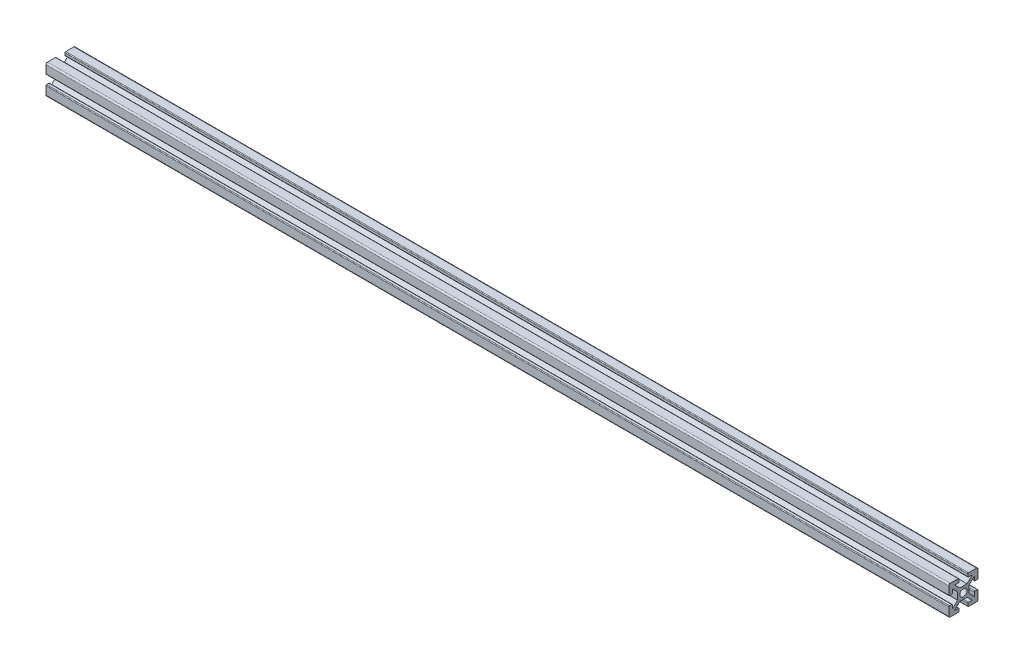
from build123d import *

# Parameters (mm, degrees)
SKETCH11_R                            = 2.5
ALUMINIUM_PROF_ALUMINIUM_PROF_1_DEPTH = 620


with BuildPart() as part:
    # Sketch11 → Aluminium prof ALUMINIUM PROF(1) (new body)
    with BuildSketch(Plane.YZ.offset(-286.350515464)):
        with BuildLine():
            Line((-2.5, 4), (2.5, 4))
            Line((2.5, 4), (6.035533906, 7.535533906))
            Line((6.035533906, 7.535533906), (3.535533906, 7.535533906))
            ThreePointArc((3.535533906, 7.535533906), (3.181980515, 7.681980515), (3.035533906, 8.035533906))
            Line((3.035533906, 8.035533906), (3.035533906, 9.535533906))
            ThreePointArc((3.035533906, 9.535533906), (3.181980515, 9.889087297), (3.535533906, 10.035533906))
            Line((3.535533906, 10.035533906), (9.035533906, 10.035533906))
            ThreePointArc((9.035533906, 10.035533906), (9.742640687, 9.742640687), (10.035533906, 9.035533906))
            Line((10.035533906, 9.035533906), (10.035533906, 3.535533906))
            ThreePointArc((10.035533906, 3.535533906), (9.889087297, 3.181980515), (9.535533906, 3.035533906))
            Line((9.535533906, 3.035533906), (8.035533906, 3.035533906))
            ThreePointArc((8.035533906, 3.035533906), (7.681980515, 3.181980515), (7.535533906, 3.535533906))
            Line((7.535533906, 3.535533906), (7.535533906, 6.035533906))
            Line((7.535533906, 6.035533906), (4, 2.5))
            Line((4, 2.5), (4, -2.5))
            Line((4, -2.5), (7.535533906, -6.035533906))
            Line((7.535533906, -6.035533906), (7.535533906, -3.535533906))
            ThreePointArc((7.535533906, -3.535533906), (7.681980515, -3.181980515), (8.035533906, -3.035533906))
            Line((8.035533906, -3.035533906), (9.535533906, -3.035533906))
            ThreePointArc((9.535533906, -3.035533906), (9.889087297, -3.181980515), (10.035533906, -3.535533906))
            Line((10.035533906, -3.535533906), (10.035533906, -9.035533906))
            ThreePointArc((10.035533906, -9.035533906), (9.742640687, -9.742640687), (9.035533906, -10.035533906))
            Line((9.035533906, -10.035533906), (3.535533906, -10.035533906))
            ThreePointArc((3.535533906, -10.035533906), (3.181980515, -9.889087297), (3.035533906, -9.535533906))
            Line((3.035533906, -9.535533906), (3.035533906, -8.035533906))
            ThreePointArc((3.035533906, -8.035533906), (3.181980515, -7.681980515), (3.535533906, -7.535533906))
            Line((3.535533906, -7.535533906), (6.035533906, -7.535533906))
            Line((6.035533906, -7.535533906), (2.5, -4))
            Line((2.5, -4), (-2.5, -4))
            Line((-2.5, -4), (-6.035533906, -7.535533906))
            Line((-6.035533906, -7.535533906), (-3.535533906, -7.535533906))
            ThreePointArc((-3.535533906, -7.535533906), (-3.181980515, -7.681980515), (-3.035533906, -8.035533906))
            Line((-3.035533906, -8.035533906), (-3.035533906, -9.535533906))
            ThreePointArc((-3.035533906, -9.535533906), (-3.181980515, -9.889087297), (-3.535533906, -10.035533906))
            Line((-3.535533906, -10.035533906), (-9.035533906, -10.035533906))
            ThreePointArc((-9.035533906, -10.035533906), (-9.742640687, -9.742640687), (-10.035533906, -9.035533906))
            Line((-10.035533906, -9.035533906), (-10.035533906, -3.535533906))
            ThreePointArc((-10.035533906, -3.535533906), (-9.889087297, -3.181980515), (-9.535533906, -3.035533906))
            Line((-9.535533906, -3.035533906), (-8.035533906, -3.035533906))
            ThreePointArc((-8.035533906, -3.035533906), (-7.681980515, -3.181980515), (-7.535533906, -3.535533906))
            Line((-7.535533906, -3.535533906), (-7.535533906, -6.035533906))
            Line((-7.535533906, -6.035533906), (-4, -2.5))
            Line((-4, -2.5), (-4, 2.5))
            Line((-4, 2.5), (-7.535533906, 6.035533906))
            Line((-7.535533906, 6.035533906), (-7.535533906, 3.535533906))
            ThreePointArc((-7.535533906, 3.535533906), (-7.681980515, 3.181980515), (-8.035533906, 3.035533906))
            Line((-8.035533906, 3.035533906), (-9.535533906, 3.035533906))
            ThreePointArc((-9.535533906, 3.035533906), (-9.889087297, 3.181980515), (-10.035533906, 3.535533906))
            Line((-10.035533906, 3.535533906), (-10.035533906, 9.035533906))
            ThreePointArc((-10.035533906, 9.035533906), (-9.742640687, 9.742640687), (-9.035533906, 10.035533906))
            Line((-9.035533906, 10.035533906), (-3.535533906, 10.035533906))
            ThreePointArc((-3.535533906, 10.035533906), (-3.181980515, 9.889087297), (-3.035533906, 9.535533906))
            Line((-3.035533906, 9.535533906), (-3.035533906, 8.035533906))
            ThreePointArc((-3.035533906, 8.035533906), (-3.181980515, 7.681980515), (-3.535533906, 7.535533906))
            Line((-3.535533906, 7.535533906), (-6.035533906, 7.535533906))
            Line((-6.035533906, 7.535533906), (-2.5, 4))
        make_face()
        Circle(SKETCH11_R, mode=Mode.SUBTRACT)
    extrude(amount=ALUMINIUM_PROF_ALUMINIUM_PROF_1_DEPTH)


solid = part.part
